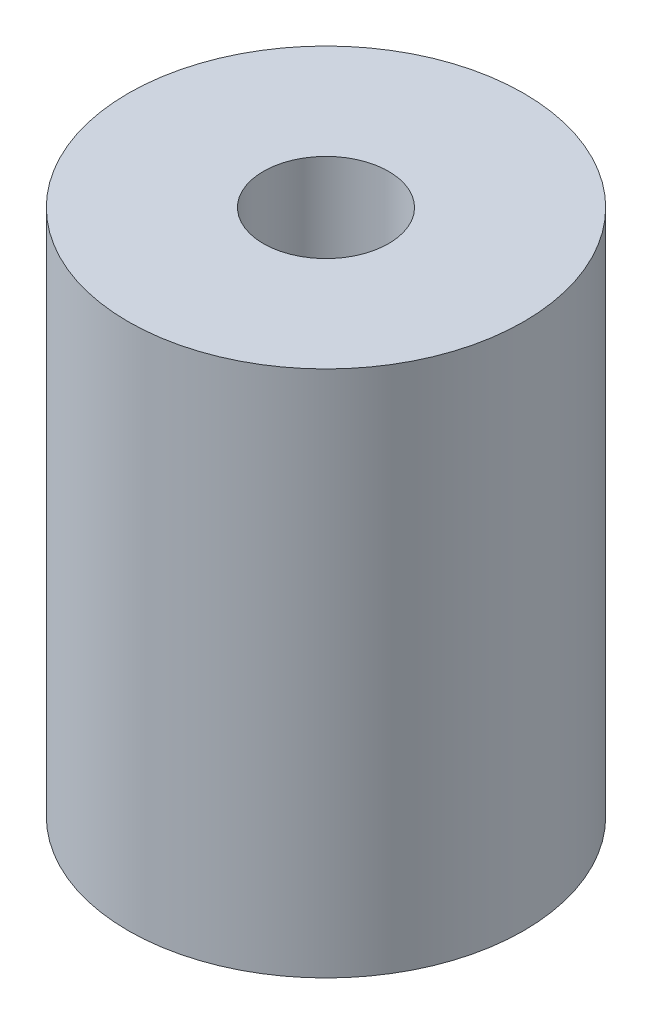
from build123d import *

# Parameters (mm, degrees)
SKETCH1_R           = 7.5
BOSS_EXTRUDE1_DEPTH = 10
SKETCH2_R           = 2.375
CUT_EXTRUDE1_DEPTH  = 9
SKETCH3_R           = 2.375
CUT_EXTRUDE2_DEPTH  = 9


with BuildPart() as part:
    # Sketch1 → Boss-Extrude1 (new body, symmetric)
    with BuildSketch(Plane(origin=(0, 0, 0), x_dir=(1, 0, 0), z_dir=(0, 1, 0))):
        Circle(SKETCH1_R)
    extrude(amount=BOSS_EXTRUDE1_DEPTH, both=True)

    # Sketch2 → Cut-Extrude1 (cut)
    with BuildSketch(Plane(origin=(0, 10, 0), x_dir=(1, 0, 0), z_dir=(0, 1, 0))):
        Circle(SKETCH2_R)
    extrude(amount=-CUT_EXTRUDE1_DEPTH, mode=Mode.SUBTRACT)

    # Sketch3 → Cut-Extrude2 (cut)
    with BuildSketch(Plane.XZ.offset(10)):
        Circle(SKETCH3_R)
    extrude(amount=-CUT_EXTRUDE2_DEPTH, mode=Mode.SUBTRACT)


solid = part.part
